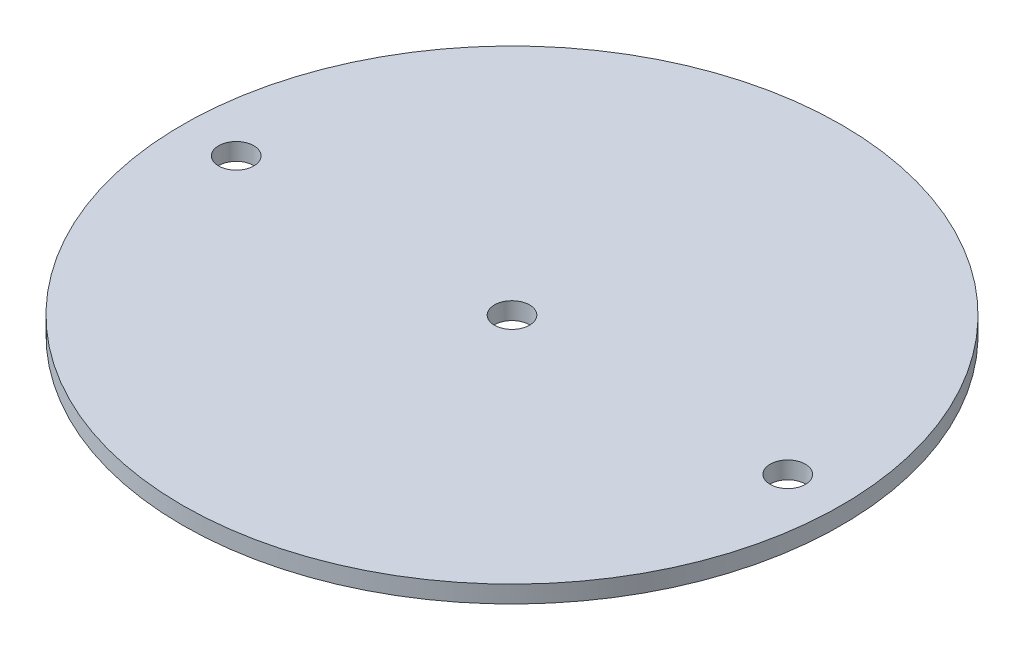
from build123d import *

# Parameters (mm, degrees)
SKETCH2_R           = 60.706
SKETCH2_R_2         = 3.2385
BOSS_EXTRUDE1_DEPTH = 3.175


with BuildPart() as part:
    # Sketch2 → Boss-Extrude1 (new body)
    with BuildSketch(Plane(origin=(0, 0, 0), x_dir=(1, 0, 0), z_dir=(0, 1, 0))):
        Circle(SKETCH2_R)
        with Locations((-50.8, 0)):
            Circle(SKETCH2_R_2, mode=Mode.SUBTRACT)
        with Locations((50.8, 0)):
            Circle(SKETCH2_R_2, mode=Mode.SUBTRACT)
        Circle(SKETCH2_R_2, mode=Mode.SUBTRACT)
    extrude(amount=BOSS_EXTRUDE1_DEPTH)


solid = part.part
